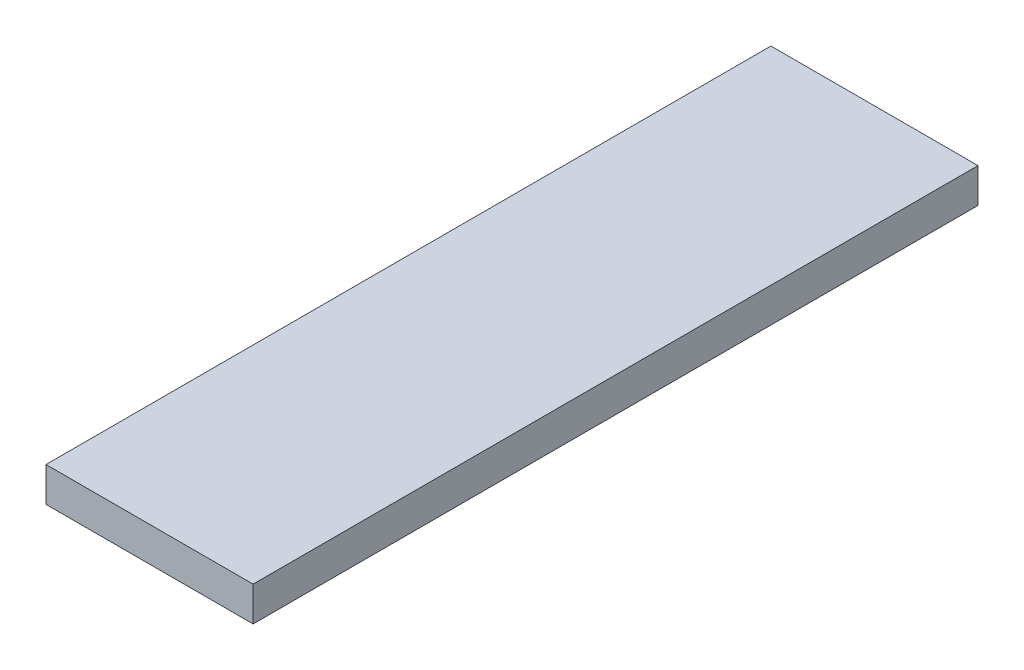
from build123d import *

# Parameters (mm, degrees)
SKETCH1_W           = 15.24
SKETCH1_H           = 2.54
BOSS_EXTRUDE1_DEPTH = 53.34


with BuildPart() as part:
    # Sketch1 → Boss-Extrude1 (new body)
    with BuildSketch(Plane.XY):
        with Locations((-7.62, 1.27)):
            Rectangle(SKETCH1_W, SKETCH1_H)
    extrude(amount=BOSS_EXTRUDE1_DEPTH)


solid = part.part
